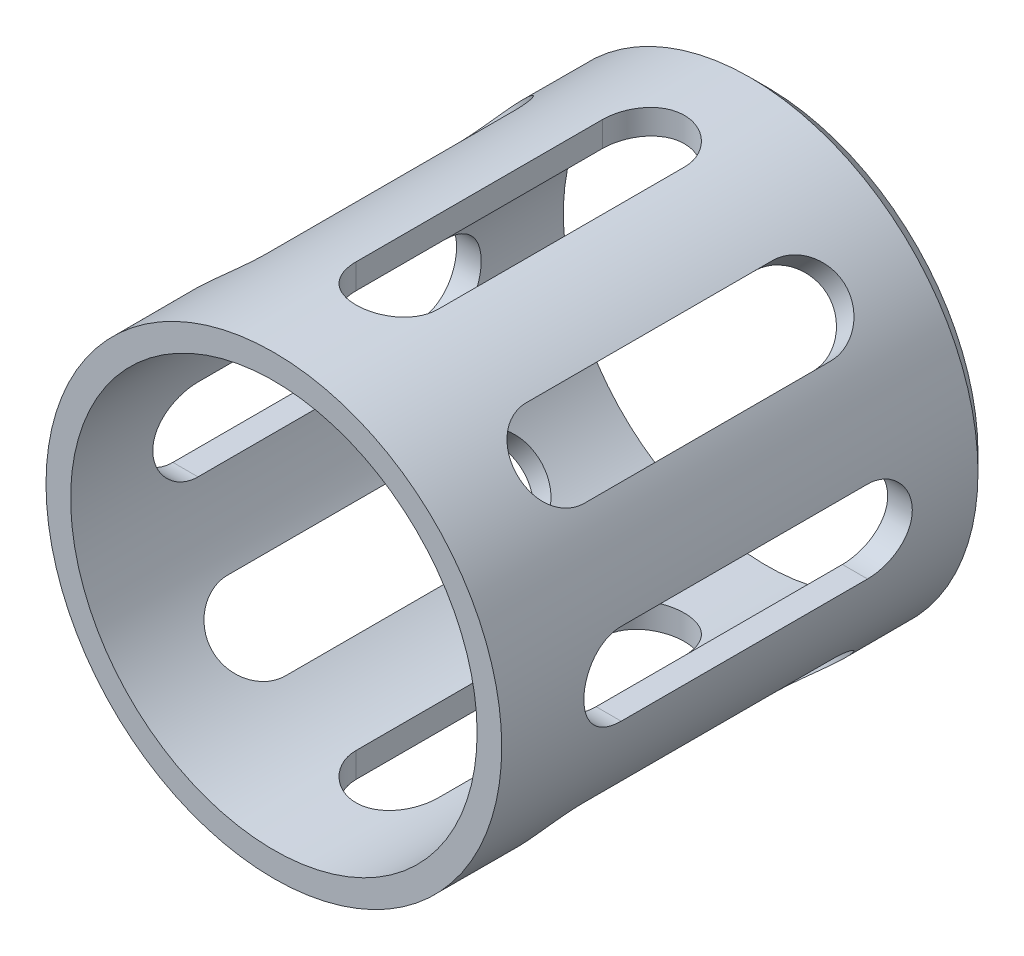
from build123d import *

# Parameters (mm, degrees)
SKETCH1_R           = 27.75
SKETCH1_R_2         = 24.75
BOSS_EXTRUDE1_DEPTH = 60
CUT_EXTRUDE1_DEPTH  = 28.75
CIRPATTERN1_COUNT   = 8
CHAMFER1_SIZE       = 2


with BuildPart() as part:
    # Sketch1 → Boss-Extrude1 (new body)
    with BuildSketch(Plane.XY):
        Circle(SKETCH1_R)
        Circle(SKETCH1_R_2, mode=Mode.SUBTRACT)
    extrude(amount=BOSS_EXTRUDE1_DEPTH)

    # Sketch2 → Cut-Extrude1 (cut, symmetric)
    with BuildSketch(Plane(origin=(0, 0, 0), x_dir=(0, 0, -1), z_dir=(1, 0, 0))):
        with BuildLine():
            ThreePointArc((-15, -5), (-11.464466094, -3.535533906), (-10, 0))
            ThreePointArc((-10, 0), (-11.464466094, 3.535533906), (-15, 5))
            Line((-15, 5), (-45, 5))
            ThreePointArc((-45, 5), (-48.535533906, 3.535533906), (-50, 0))
            ThreePointArc((-50, 0), (-48.535533906, -3.535533906), (-45, -5))
            Line((-45, -5), (-15, -5))
        make_face()
    cut_extrude1 = extrude(amount=CUT_EXTRUDE1_DEPTH, both=True, mode=Mode.SUBTRACT)

    # CirPattern1: Cut-Extrude1 ×8 about axis
    cirpattern1_axis = Axis((0, 0, 0), (0, 0, 1))
    for i in range(1, CIRPATTERN1_COUNT):
        add(cut_extrude1.rotate(cirpattern1_axis, i * 360 / CIRPATTERN1_COUNT), mode=Mode.SUBTRACT)

    # Chamfer1
    chamfer1_edges = [part.edges().sort_by_distance(p)[0] for p in [
        (-27.75, 0, 0),
    ]]
    chamfer(chamfer1_edges, length=CHAMFER1_SIZE)


solid = part.part
